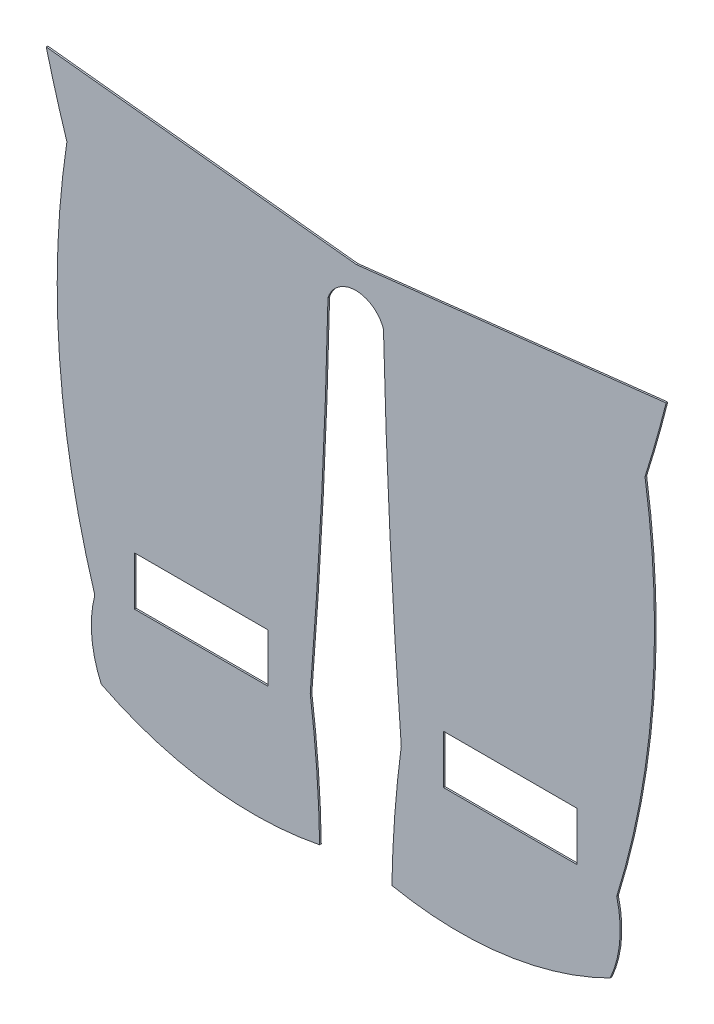
from build123d import *

# Parameters (mm, degrees)
MODEL_W                 = 8.2
MODEL_H                 = 3
SALIENTE_EXTRUIR1_DEPTH = 0.1


with BuildPart() as part:
    # Model → Saliente-Extruir1 (new body)
    with BuildSketch(Plane.XY):
        with BuildLine():
            Line((38.133331438, 3.018818363), (57.179927809, 5.173191598))
            ThreePointArc((57.179927809, 5.173191598), (56.564184394, 2.876430864), (55.882023409, 0.598513786))
            ThreePointArc((55.882023409, 0.598513786), (56.320793695, -11.111458732), (54.141567414, -22.625230857))
            ThreePointArc((54.141567414, -22.625230857), (54.328024919, -24.933799392), (53.741439305, -27.174373514))
            ThreePointArc((53.741439305, -27.174373514), (47.17770756, -29.193874015), (40.314312824, -28.959845377))
            ThreePointArc((40.314312824, -28.959845377), (40.492148067, -25.099981333), (40.891508653, -21.256716194))
            ThreePointArc((40.891508653, -21.256716194), (40.199471936, -10.428965006), (39.796709943, 0.413400668))
            ThreePointArc((39.796709943, 0.413400668), (38.077330395, 1.62185217), (36.383150384, 0.378318835))
            ThreePointArc((36.383150384, 0.378318835), (35.993185815, -10.447336237), (35.292291091, -21.257314345))
            ThreePointArc((35.292291091, -21.257314345), (35.69426102, -25.128822948), (35.871435139, -29.017108947))
            ThreePointArc((35.871435139, -29.017108947), (29.002751827, -29.224427494), (22.443184445, -27.176534138))
            ThreePointArc((22.443184445, -27.176534138), (21.856306031, -24.936090235), (22.042444158, -22.627547891))
            ThreePointArc((22.042444158, -22.627547891), (19.872780358, -11.081256605), (20.328112859, 0.658290054))
            ThreePointArc((20.328112859, 0.658290054), (19.658091011, 2.85533825), (19.057482139, 5.072367576))
            Line((19.057482139, 5.072367576), (38.133331438, 3.018818363))
        make_face()
        with Locations((28.59004178, -20.657297672)):
            Rectangle(MODEL_W, MODEL_H, mode=Mode.SUBTRACT)
        with Locations((47.59004178, -20.657297672)):
            Rectangle(MODEL_W, MODEL_H, mode=Mode.SUBTRACT)
    extrude(amount=SALIENTE_EXTRUIR1_DEPTH)


solid = part.part
